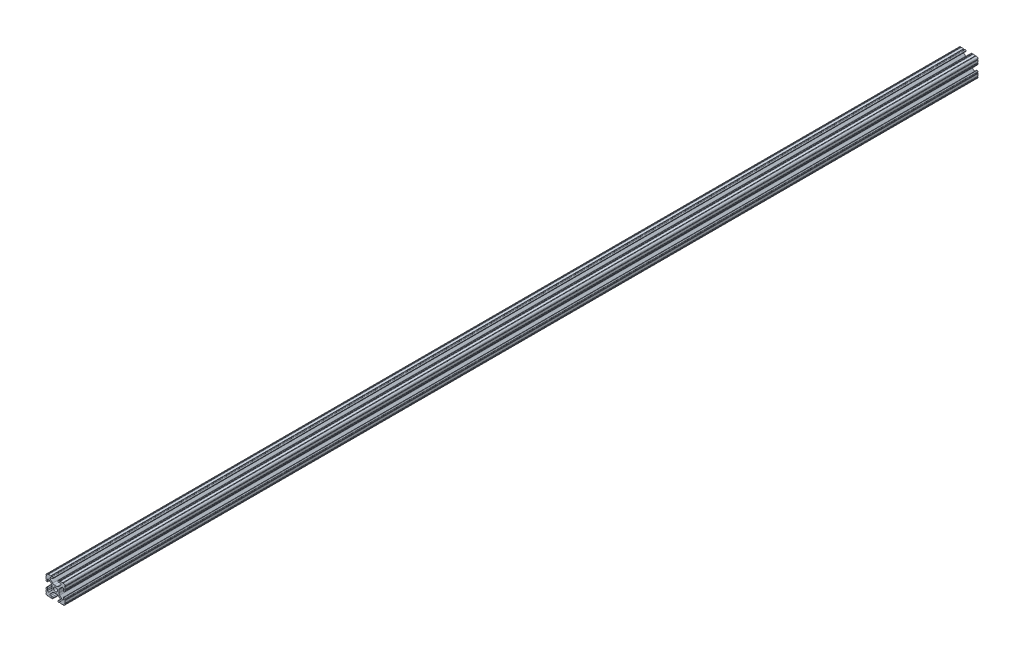
from build123d import *

# Parameters (mm, degrees)
SKETCH1_R               = 2.6035
BOSS_EXTRUDE1_DEPTH     = 609.6
SKETCH2_R               = 3.175
CUT_EXTRUDE1_DEPTH      = 610.975067091
CUT_EXTRUDE1_DEPTH_BACK = 610.975067091
SKETCH3_R               = 3.175
CUT_EXTRUDE2_DEPTH      = 610.974709033
CUT_EXTRUDE2_DEPTH_BACK = 610.974709033


with BuildPart() as part:
    # Sketch1 → Boss-Extrude1 (new, symmetric)
    with BuildSketch(Plane.XY):
        with BuildLine():
            Line((-7.179650497, -8.645192506), (-3.952270251, -5.423690499))
            ThreePointArc((-3.952270251, -5.423690499), (-2.922936451, -4.736929036), (-1.709253557, -4.4958))
            Line((-1.709253557, -4.4958), (1.709253557, -4.4958))
            ThreePointArc((1.709253557, -4.4958), (2.922936451, -4.736929036), (3.952270251, -5.423690499))
            Line((3.952270251, -5.423690499), (7.179650497, -8.645192506))
            ThreePointArc((7.179650497, -8.645192506), (7.41473083, -9.822813117), (6.416408329, -10.4902))
            Line((6.416408329, -10.4902), (4.287512407, -10.4902))
            ThreePointArc((4.287512407, -10.4902), (3.54574862, -10.79744862), (3.2385, -11.539212407))
            Line((3.2385, -11.539212407), (3.2385, -11.650987593))
            ThreePointArc((3.2385, -11.650987593), (3.54574862, -12.39275138), (4.287512407, -12.7))
            Line((4.287512407, -12.7), (5.317126718, -12.7))
            ThreePointArc((5.317126718, -12.7), (5.825126718, -12.192), (6.333126718, -12.7))
            Line((6.333126718, -12.7), (9.550443118, -12.7))
            ThreePointArc((9.550443118, -12.7), (10.058366869, -12.192000006), (10.566443095, -12.699847501))
            ThreePointArc((10.566443095, -12.699847501), (12.082537762, -12.08250727), (12.699846982, -10.566399977))
            ThreePointArc((12.699846982, -10.566399977), (12.192000006, -10.058323491), (12.7, -9.5504))
            Line((12.7, -9.5504), (12.7, -6.3330836))
            ThreePointArc((12.7, -6.3330836), (12.192, -5.8250836), (12.7, -5.3170836))
            Line((12.7, -5.3170836), (12.7, -4.287469289))
            ThreePointArc((12.7, -4.287469289), (12.39275138, -3.545705502), (11.650987593, -3.238456882))
            Line((11.650987593, -3.238456882), (11.539212407, -3.238456882))
            ThreePointArc((11.539212407, -3.238456882), (10.79744862, -3.545705502), (10.4902, -4.287469289))
            Line((10.4902, -4.287469289), (10.4902, -6.402089023))
            ThreePointArc((10.4902, -6.402089023), (9.856505071, -7.351067942), (8.737131347, -7.129408934))
            Line((8.737131347, -7.129408934), (5.441005833, -3.840816462))
            ThreePointArc((5.441005833, -3.840816462), (4.750877967, -2.809883091), (4.5085, -1.593185507))
            Line((4.5085, -1.593185507), (4.5085, 1.593185507))
            ThreePointArc((4.5085, 1.593185507), (4.750877967, 2.809883091), (5.441005833, 3.840816462))
            Line((5.441005833, 3.840816462), (8.737131347, 7.129408934))
            ThreePointArc((8.737131347, 7.129408934), (9.856505071, 7.351067942), (10.4902, 6.402089023))
            Line((10.4902, 6.402089023), (10.4902, 4.287469289))
            ThreePointArc((10.4902, 4.287469289), (10.79744862, 3.545705502), (11.539212407, 3.238456882))
            Line((11.539212407, 3.238456882), (11.650987593, 3.238456882))
            ThreePointArc((11.650987593, 3.238456882), (12.39275138, 3.545705502), (12.7, 4.287469289))
            Line((12.7, 4.287469289), (12.7, 5.3170836))
            ThreePointArc((12.7, 5.3170836), (12.192, 5.8250836), (12.7, 6.3330836))
            Line((12.7, 6.3330836), (12.7, 9.5504))
            ThreePointArc((12.7, 9.5504), (12.192000006, 10.058323491), (12.699846982, 10.566399977))
            ThreePointArc((12.699846982, 10.566399977), (12.082537762, 12.08250727), (10.566443095, 12.699847501))
            ThreePointArc((10.566443095, 12.699847501), (10.058366869, 12.192000006), (9.550443118, 12.7))
            Line((9.550443118, 12.7), (6.333126718, 12.7))
            ThreePointArc((6.333126718, 12.7), (5.825126718, 12.192), (5.317126718, 12.7))
            Line((5.317126718, 12.7), (4.287512407, 12.7))
            ThreePointArc((4.287512407, 12.7), (3.54574862, 12.39275138), (3.2385, 11.650987593))
            Line((3.2385, 11.650987593), (3.2385, 11.539212407))
            ThreePointArc((3.2385, 11.539212407), (3.54574862, 10.79744862), (4.287512407, 10.4902))
            Line((4.287512407, 10.4902), (6.476788598, 10.4902))
            ThreePointArc((6.476788598, 10.4902), (7.432222385, 9.85140422), (7.207036008, 8.724370562))
            Line((7.207036008, 8.724370562), (3.898272566, 5.423169045))
            ThreePointArc((3.898272566, 5.423169045), (2.869120213, 4.736787962), (1.655778399, 4.4958))
            Line((1.655778399, 4.4958), (-1.655778399, 4.4958))
            ThreePointArc((-1.655778399, 4.4958), (-2.869120213, 4.736787962), (-3.898272566, 5.423169045))
            Line((-3.898272566, 5.423169045), (-7.207036008, 8.724370562))
            ThreePointArc((-7.207036008, 8.724370562), (-7.432222385, 9.85140422), (-6.476788598, 10.4902))
            Line((-6.476788598, 10.4902), (-4.287512407, 10.4902))
            ThreePointArc((-4.287512407, 10.4902), (-3.54574862, 10.79744862), (-3.2385, 11.539212407))
            Line((-3.2385, 11.539212407), (-3.2385, 11.650987593))
            ThreePointArc((-3.2385, 11.650987593), (-3.54574862, 12.39275138), (-4.287512407, 12.7))
            Line((-4.287512407, 12.7), (-5.317126718, 12.7))
            ThreePointArc((-5.317126718, 12.7), (-5.825126718, 12.192), (-6.333126718, 12.7))
            Line((-6.333126718, 12.7), (-9.550443118, 12.7))
            ThreePointArc((-9.550443118, 12.7), (-10.058366869, 12.192000006), (-10.566443095, 12.699847501))
            ThreePointArc((-10.566443095, 12.699847501), (-12.082537762, 12.08250727), (-12.699846982, 10.566399977))
            ThreePointArc((-12.699846982, 10.566399977), (-12.192000006, 10.058323491), (-12.7, 9.5504))
            Line((-12.7, 9.5504), (-12.7, 6.3330836))
            ThreePointArc((-12.7, 6.3330836), (-12.192, 5.8250836), (-12.7, 5.3170836))
            Line((-12.7, 5.3170836), (-12.7, 4.287469289))
            ThreePointArc((-12.7, 4.287469289), (-12.39275138, 3.545705502), (-11.650987593, 3.238456882))
            Line((-11.650987593, 3.238456882), (-11.539212407, 3.238456882))
            ThreePointArc((-11.539212407, 3.238456882), (-10.79744862, 3.545705502), (-10.4902, 4.287469289))
            Line((-10.4902, 4.287469289), (-10.4902, 6.402089023))
            ThreePointArc((-10.4902, 6.402089023), (-9.856505071, 7.351067942), (-8.737131347, 7.129408934))
            Line((-8.737131347, 7.129408934), (-5.441005833, 3.840816462))
            ThreePointArc((-5.441005833, 3.840816462), (-4.750877967, 2.809883091), (-4.5085, 1.593185507))
            Line((-4.5085, 1.593185507), (-4.5085, -1.593185507))
            ThreePointArc((-4.5085, -1.593185507), (-4.750877967, -2.809883091), (-5.441005833, -3.840816462))
            Line((-5.441005833, -3.840816462), (-8.737131347, -7.129408934))
            ThreePointArc((-8.737131347, -7.129408934), (-9.856505071, -7.351067942), (-10.4902, -6.402089023))
            Line((-10.4902, -6.402089023), (-10.4902, -4.287469289))
            ThreePointArc((-10.4902, -4.287469289), (-10.79744862, -3.545705502), (-11.539212407, -3.238456882))
            Line((-11.539212407, -3.238456882), (-11.650987593, -3.238456882))
            ThreePointArc((-11.650987593, -3.238456882), (-12.39275138, -3.545705502), (-12.7, -4.287469289))
            Line((-12.7, -4.287469289), (-12.7, -5.3170836))
            ThreePointArc((-12.7, -5.3170836), (-12.192, -5.8250836), (-12.7, -6.3330836))
            Line((-12.7, -6.3330836), (-12.7, -9.5504))
            ThreePointArc((-12.7, -9.5504), (-12.192000006, -10.058323491), (-12.699846982, -10.566399977))
            ThreePointArc((-12.699846982, -10.566399977), (-12.082537762, -12.08250727), (-10.566443095, -12.699847501))
            ThreePointArc((-10.566443095, -12.699847501), (-10.058366869, -12.192000006), (-9.550443118, -12.7))
            Line((-9.550443118, -12.7), (-6.333126718, -12.7))
            ThreePointArc((-6.333126718, -12.7), (-5.825126718, -12.192), (-5.317126718, -12.7))
            Line((-5.317126718, -12.7), (-4.287512407, -12.7))
            ThreePointArc((-4.287512407, -12.7), (-3.54574862, -12.39275138), (-3.2385, -11.650987593))
            Line((-3.2385, -11.650987593), (-3.2385, -11.539212407))
            ThreePointArc((-3.2385, -11.539212407), (-3.54574862, -10.79744862), (-4.287512407, -10.4902))
            Line((-4.287512407, -10.4902), (-6.416408329, -10.4902))
            ThreePointArc((-6.416408329, -10.4902), (-7.41473083, -9.822813117), (-7.179650497, -8.645192506))
        make_face()
        with Locations(Location((0, 0, 0), (0, 0, 180))):
            Circle(SKETCH1_R, mode=Mode.SUBTRACT)
    extrude(amount=BOSS_EXTRUDE1_DEPTH, both=True)

    # Sketch2 → Cut-Extrude1 (cut, two sides)
    with BuildSketch(Plane(origin=(4.5085, 0, 0), x_dir=(0, 0, -1), z_dir=(1, 0, 0))) as cut_extrude1_sk:
        with Locations(Location((38.1, 0, 0), (0, 0, 30.11854336))):
            Circle(SKETCH2_R)
        with Locations(Location((-38.1, 0, 0), (0, 0, 30.11854336))):
            Circle(SKETCH2_R)
        with Locations(Location((0, 0, 0), (0, 0, 30.11854336))):
            Circle(SKETCH2_R)
    extrude(amount=CUT_EXTRUDE1_DEPTH, mode=Mode.SUBTRACT)
    extrude(cut_extrude1_sk.sketch, amount=-CUT_EXTRUDE1_DEPTH_BACK, mode=Mode.SUBTRACT)

    # Sketch3 → Cut-Extrude2 (cut, two sides)
    with BuildSketch(Plane(origin=(0, 4.4958, 0), x_dir=(1, 0, 0), z_dir=(0, 1, 0))) as cut_extrude2_sk:
        with Locations(Location((0, 330.2, 0), (0, 0, 237.428778052))):
            Circle(SKETCH3_R)
        with Locations(Location((0, -330.2, 0), (0, 0, 237.428778052))):
            Circle(SKETCH3_R)
    extrude(amount=CUT_EXTRUDE2_DEPTH, mode=Mode.SUBTRACT)
    extrude(cut_extrude2_sk.sketch, amount=-CUT_EXTRUDE2_DEPTH_BACK, mode=Mode.SUBTRACT)


solid = part.part
